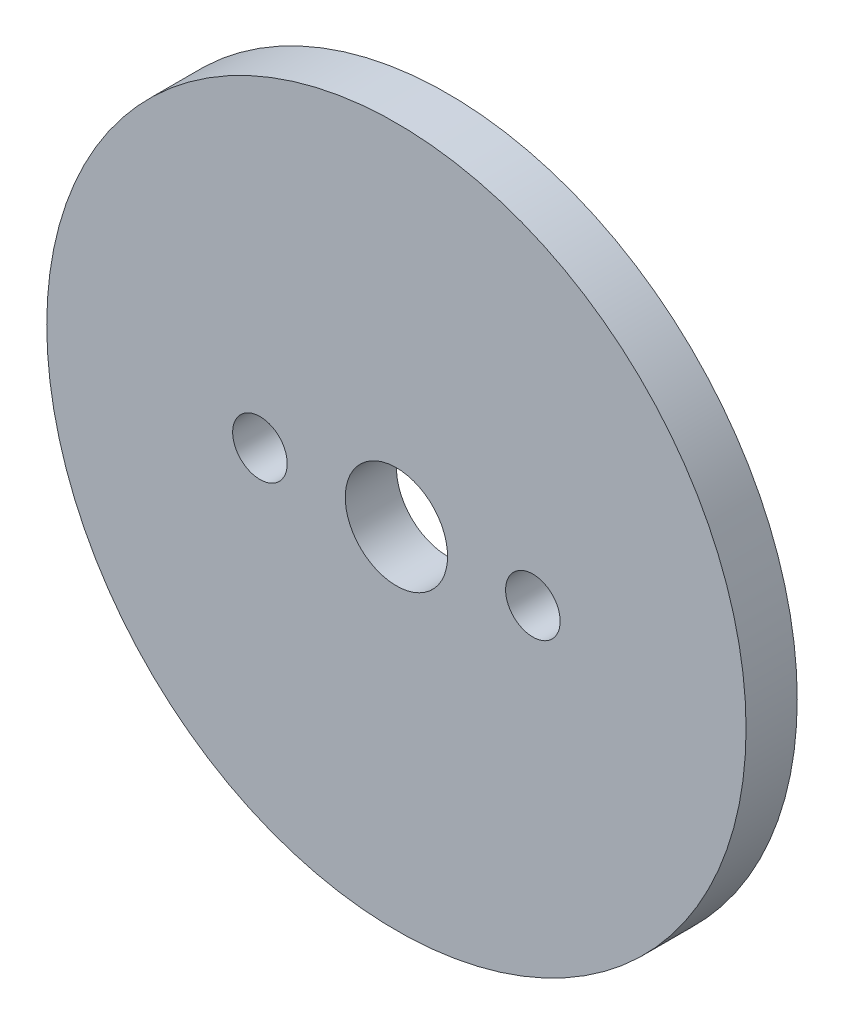
from build123d import *

# Parameters (mm, degrees)
ESBO_O1_R                = 20.5
ESBO_O1_R_2              = 3
ESBO_O1_R_3              = 1.6
RESSALTO_EXTRUS_O1_DEPTH = 1.5


with BuildPart() as part:
    # Esboço1 → Ressalto-extrusão1 (new body, symmetric)
    with BuildSketch(Plane.XY):
        Circle(ESBO_O1_R)
        Circle(ESBO_O1_R_2, mode=Mode.SUBTRACT)
        with Locations((-8, 0)):
            Circle(ESBO_O1_R_3, mode=Mode.SUBTRACT)
        with Locations((8, 0)):
            Circle(ESBO_O1_R_3, mode=Mode.SUBTRACT)
    extrude(amount=RESSALTO_EXTRUS_O1_DEPTH, both=True)


solid = part.part
